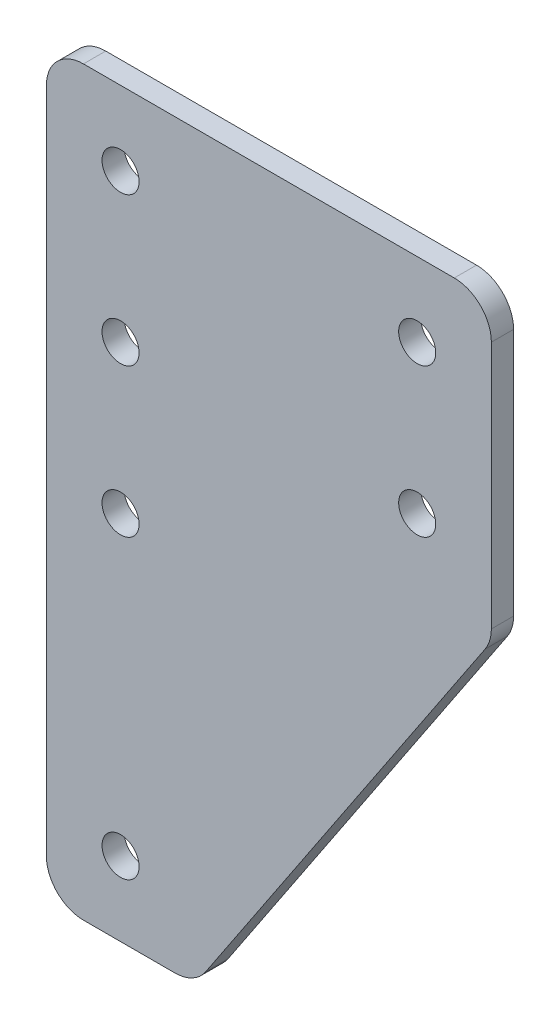
from build123d import *

# Parameters (mm, degrees)
BOSS_EXTRUDE1_DEPTH  = 3
SKETCH3_R            = 2.5
CUT_EXTRUDE1_DEPTH   = 4
LPATTERN1_COUNT      = 2
LPATTERN1_PITCH      = 40
LPATTERN1_COUNT_DIR2 = 2
LPATTERN1_PITCH_DIR2 = 20
SKETCH4_R            = 2.5
CUT_EXTRUDE2_DEPTH   = 4
LPATTERN2_COUNT      = 2
LPATTERN2_PITCH      = 40
FILLET1_R            = 5


with BuildPart() as part:
    # Sketch1 → Boss-Extrude1 (new body)
    with BuildSketch(Plane.XY):
        Polygon((0, 0), (20, 0), (60, 60), (60, 100), (0, 100), align=None)
    extrude(amount=BOSS_EXTRUDE1_DEPTH)

    # Sketch3 → Cut-Extrude1 (cut, through all)
    with BuildSketch(Plane.XY.offset(3)):
        with Locations((50, 90)):
            Circle(SKETCH3_R)
    cut_extrude1 = extrude(amount=-CUT_EXTRUDE1_DEPTH, mode=Mode.SUBTRACT)

    # LPattern1: Cut-Extrude1 2 × 2
    with Locations(*[(-i * LPATTERN1_PITCH, -j * LPATTERN1_PITCH_DIR2, 0) for i in range(LPATTERN1_COUNT) for j in range(LPATTERN1_COUNT_DIR2) if (i, j) != (0, 0)]):
        add(cut_extrude1, mode=Mode.SUBTRACT)

    # Sketch4 → Cut-Extrude2 (cut, through all)
    with BuildSketch(Plane.XY.offset(3)):
        with Locations((10, 10)):
            Circle(SKETCH4_R)
    cut_extrude2 = extrude(amount=-CUT_EXTRUDE2_DEPTH, mode=Mode.SUBTRACT)

    # LPattern2: Cut-Extrude2 ×2
    with Locations(*[(0, i * LPATTERN2_PITCH, 0) for i in range(1, LPATTERN2_COUNT)]):
        add(cut_extrude2, mode=Mode.SUBTRACT)

    # Fillet1
    fillet1_edges = [part.edges().sort_by_distance(p)[0] for p in [
        (0, 100, 1.5),
        (60, 100, 1.5),
        (60, 60, 1.5),
        (20, 0, 1.5),
        (0, 0, 1.5),
    ]]
    fillet(fillet1_edges, radius=FILLET1_R)


solid = part.part
